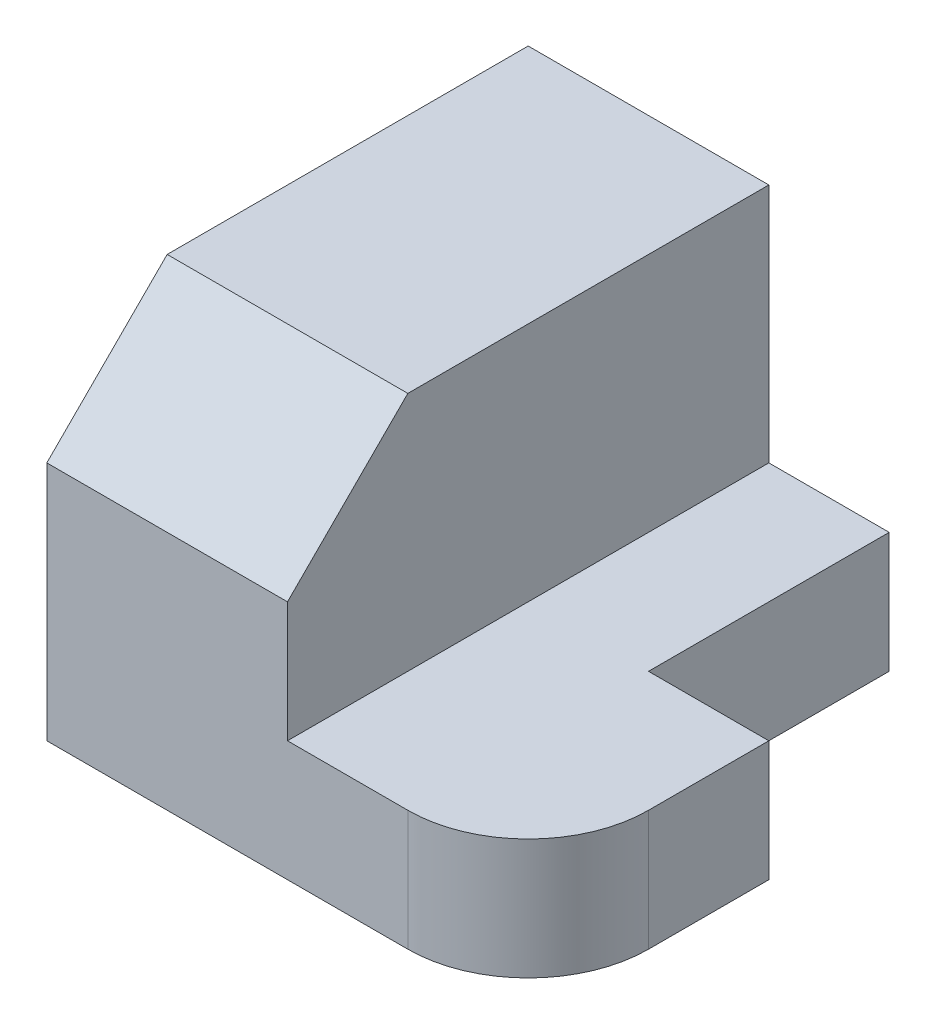
from build123d import *

# Parameters (mm, degrees)
EXTRUDE_1_DEPTH     = 5
SKETCH_1_3_W        = 10
SKETCH_1_3_H        = 20
EXTRUDE_2_DEPTH     = 15
CUT_EXTRUDE_1_DEPTH = 15


with BuildPart() as part:
    # 草圖1 → 填料-伸長1 (new body)
    with BuildSketch(Plane(origin=(0, 0, 0), x_dir=(1, 0, 0), z_dir=(0, 1, 0))):
        with BuildLine():
            Line((10, 10), (5, 10))
            Line((5, 10), (5, -5))
            Line((5, -5), (5, -10))
            Line((5, -10), (10, -10))
            ThreePointArc((10, -10), (13.535533906, -8.535533906), (15, -5))
            Line((15, -5), (15, 0))
            Line((15, 0), (10, 0))
            Line((10, 0), (10, 10))
        make_face()
    extrude(amount=EXTRUDE_1_DEPTH)

    # 草圖1<3> → 填料-伸長2 (add)
    with BuildSketch(Plane(origin=(0, 0, 0), x_dir=(1, 0, 0), z_dir=(0, 1, 0))):
        Rectangle(SKETCH_1_3_W, SKETCH_1_3_H)
    extrude(amount=EXTRUDE_2_DEPTH)

    # 草圖2 → 除料-伸長1 (cut)
    with BuildSketch(Plane.ZY.offset(5)):
        Polygon((5, 15), (10, 10), (10, 15), align=None)
    extrude(amount=-CUT_EXTRUDE_1_DEPTH, mode=Mode.SUBTRACT)


solid = part.part
